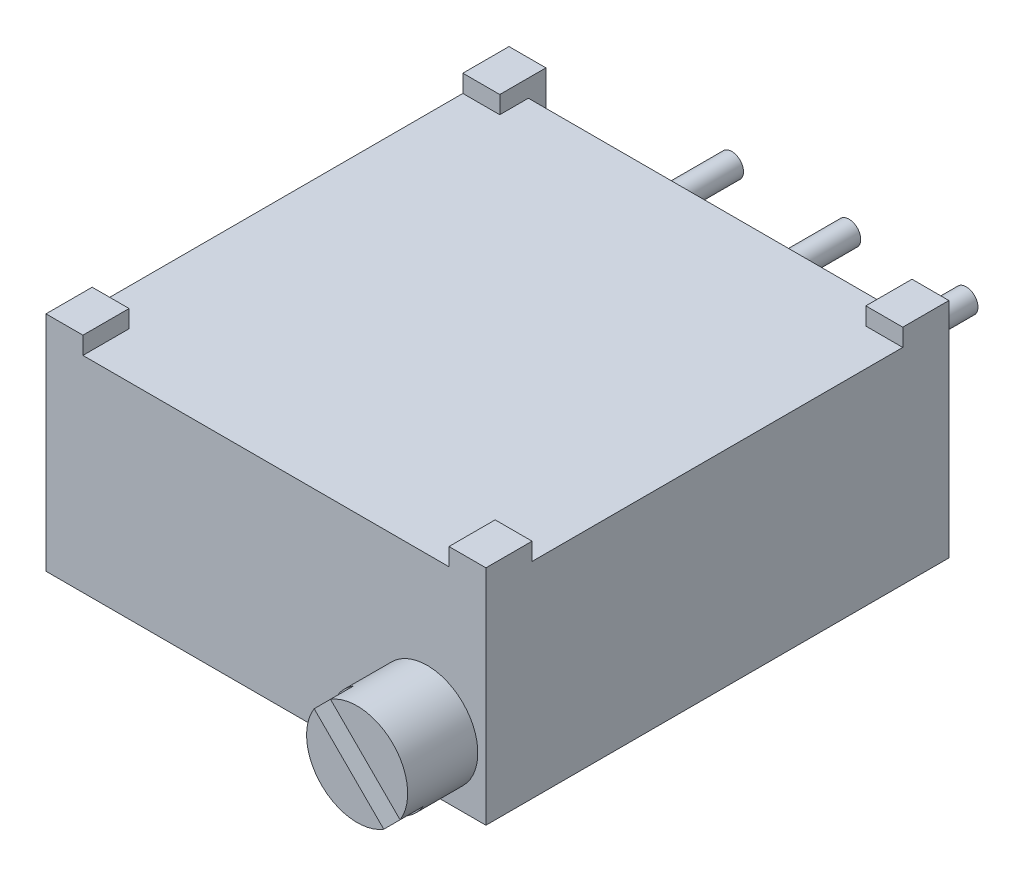
from build123d import *

# Parameters (mm, degrees)
ESBO_O1_W                = 9.53
ESBO_O1_H                = 10.03
RESSALTO_EXTRUS_O1_DEPTH = 2.415
CORTE_EXTRUS_O1_REACH    = 6.83
ESBO_O2_W                = 7.93
ESBO_O2_H                = 1
CORTE_EXTRUS_O2_DEPTH    = 0.38
ESBO_O4_R                = 1.095
RESSALTO_EXTRUS_O2_DEPTH = 1.52
CORTE_EXTRUS_O3_DEPTH    = 0.5
ESBO_O6_R                = 0.255
RESSALTO_EXTRUS_O3_DEPTH = 2.98


with BuildPart() as part:
    # Esboço1 → Ressalto-extrusão1 (new body, symmetric)
    with BuildSketch(Plane(origin=(0, 0, 0), x_dir=(1, 0, 0), z_dir=(0, 1, 0))):
        with Locations((0, -5.015)):
            Rectangle(ESBO_O1_W, ESBO_O1_H)
    extrude(amount=RESSALTO_EXTRUS_O1_DEPTH, both=True)

    # Esboço2 → Corte-extrusão1 (cut, up to next)
    with BuildSketch(Plane(origin=(0, -2.415, 0), x_dir=(-1, 0, 0), z_dir=(0, -1, 0)), mode=Mode.PRIVATE) as corte_extrus_o1_sk1:
        with Locations((0, 0.12)):
            Rectangle(ESBO_O2_W, ESBO_O2_H)
    corte_extrus_o1_tool1 = extrude(corte_extrus_o1_sk1.sketch, amount=-CORTE_EXTRUS_O1_REACH, mode=Mode.PRIVATE) & part.part
    add(corte_extrus_o1_tool1.solids().sort_by_distance((0, -2.415, -0.12))[0], mode=Mode.SUBTRACT)

    # Esboço3 → Corte-extrusão2 (cut)
    with BuildSketch(Plane(origin=(0, 2.415, 0), x_dir=(1, 0, 0), z_dir=(0, 1, 0))):
        Polygon((3.965, -0.38), (-3.965, -0.38), (-3.965, -1), (-4.765, -1), (-4.765, -9.03), (-3.965, -9.03), (-3.965, -10.03), (3.965, -10.03), (3.965, -9.03), (4.765, -9.03), (4.765, -1), (3.965, -1), align=None)
    extrude(amount=-CORTE_EXTRUS_O2_DEPTH, mode=Mode.SUBTRACT)

    # Esboço4 → Ressalto-extrusão2 (add)
    with BuildSketch(Plane.XY.offset(10.03)):
        with Locations((3.495, -1.145)):
            Circle(ESBO_O4_R)
    extrude(amount=RESSALTO_EXTRUS_O2_DEPTH)

    # Esboço5 → Corte-extrusão3 (cut)
    with BuildSketch(Plane.XY.offset(11.55)):
        with BuildLine():
            Line((2.917944817, -0.214391427), (4.425608573, -1.722055183))
            ThreePointArc((4.425608573, -1.722055183), (4.269281925, -1.919281925), (4.072055183, -2.075608573))
            Line((4.072055183, -2.075608573), (2.564391427, -0.567944817))
            ThreePointArc((2.564391427, -0.567944817), (2.720718075, -0.370718075), (2.917944817, -0.214391427))
        make_face()
    extrude(amount=-CORTE_EXTRUS_O3_DEPTH, mode=Mode.SUBTRACT)

    # Esboço6 → Ressalto-extrusão3 (add)
    with BuildSketch(Plane(origin=(0, 0, 0.38), x_dir=(-1, 0, 0), z_dir=(0, 0, -1))):
        with Locations((0, 0.005)):
            Circle(ESBO_O6_R)
        with Locations((-2.54, 0.005)):
            Circle(ESBO_O6_R)
        with Locations((2.54, 0.005)):
            Circle(ESBO_O6_R)
    extrude(amount=RESSALTO_EXTRUS_O3_DEPTH)


solid = part.part
